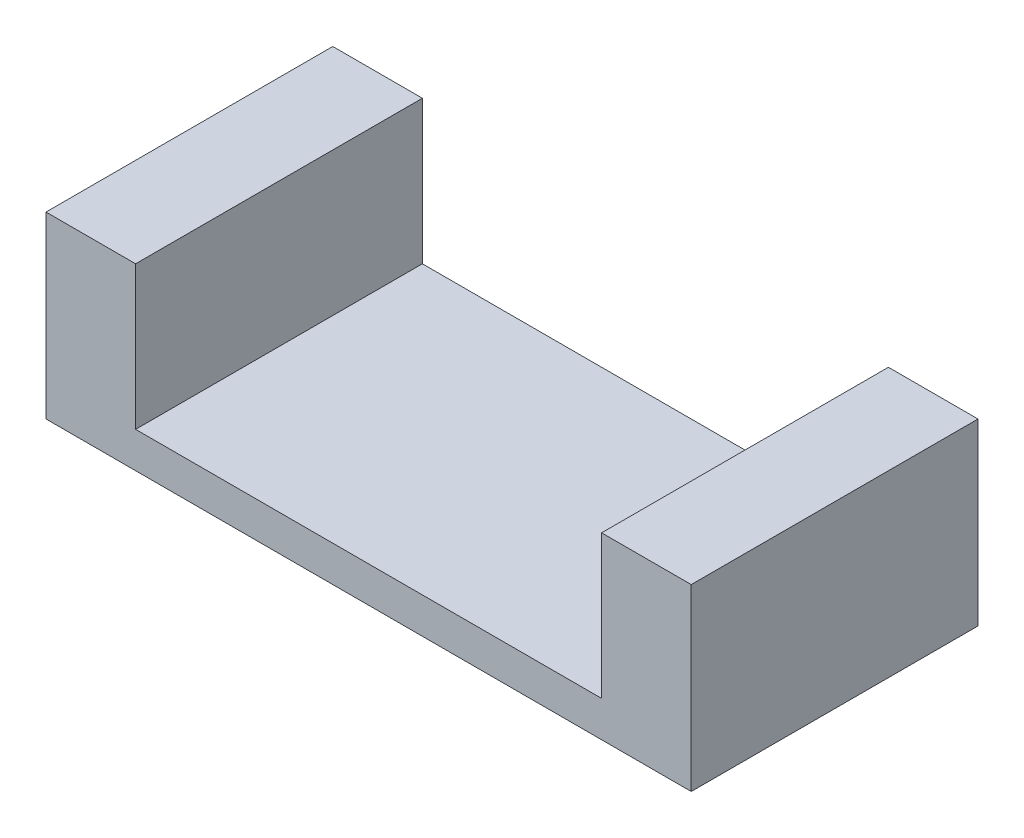
from build123d import *

# Parameters (mm, degrees)
BOSS_EXTRUDE3_DEPTH = 1.6


with BuildPart() as part:
    # Sketch4 → Boss-Extrude3 (new body)
    with BuildSketch(Plane.XY):
        Polygon((-3.6, 1), (-3.1, 1), (-3.1, 0.2), (-0.5, 0.2), (-0.5, 1), (0, 1), (0, 0), (-3.6, 0), align=None)
    extrude(amount=BOSS_EXTRUDE3_DEPTH)


solid = part.part
